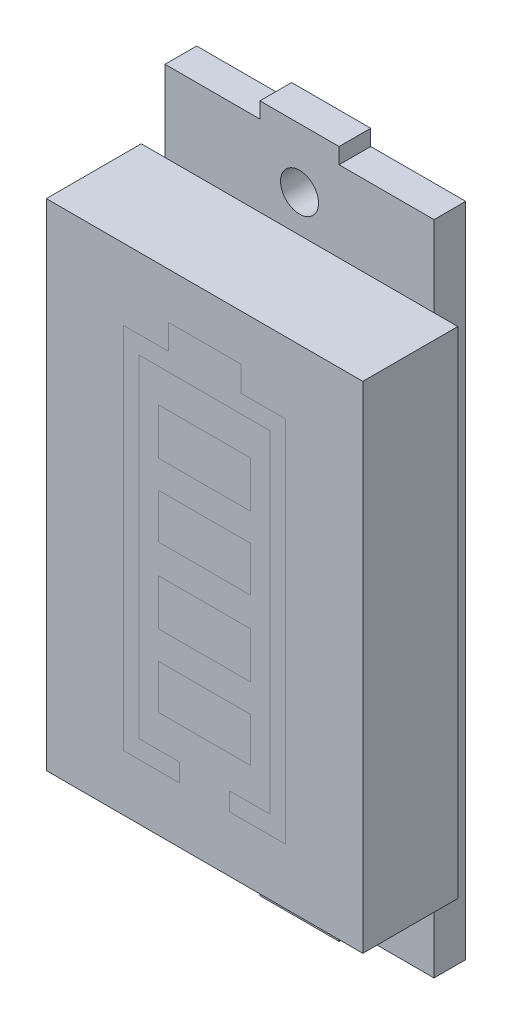
from build123d import *

# Parameters (mm, degrees)
SKETCH1_W                = 20
SKETCH1_H                = 31.3
BOSS_EXTRUDE1_DEPTH      = 6
SKETCH2_W                = 17
SKETCH2_H                = 41.5
BOSS_EXTRUDE2_DEPTH      = 2
SKETCH3_W                = 5
SKETCH3_H                = 43.5
BOSS_EXTRUDE3_DEPTH      = 2
M2_CLEARANCE_HOLE1_D     = 2.4
M2_CLEARANCE_HOLE1_DEPTH = 2


with BuildPart() as part:
    # Sketch1 → Boss-Extrude1 (new body)
    with BuildSketch(Plane.XY):
        Rectangle(SKETCH1_W, SKETCH1_H)
    extrude(amount=BOSS_EXTRUDE1_DEPTH)

    # Sketch2 → Boss-Extrude2 (add)
    with BuildSketch(Plane(origin=(0, 0, 0), x_dir=(-1, 0, 0), z_dir=(0, 0, -1))):
        Rectangle(SKETCH2_W, SKETCH2_H)
    extrude(amount=BOSS_EXTRUDE2_DEPTH)

    # Sketch3 → Boss-Extrude3 (add)
    with BuildSketch(Plane(origin=(0, 0, -2), x_dir=(-1, 0, 0), z_dir=(0, 0, -1))):
        Rectangle(SKETCH3_W, SKETCH3_H)
    extrude(amount=-BOSS_EXTRUDE3_DEPTH)

    # M2 Clearance Hole1
    with Locations(Plane(origin=(0, 0, -2), x_dir=(-1, 0, 0), z_dir=(0, 0, -1))):
        with Locations((0, 18), (0, -18)):
            Hole(M2_CLEARANCE_HOLE1_D / 2, depth=M2_CLEARANCE_HOLE1_DEPTH)


solid = part.part
